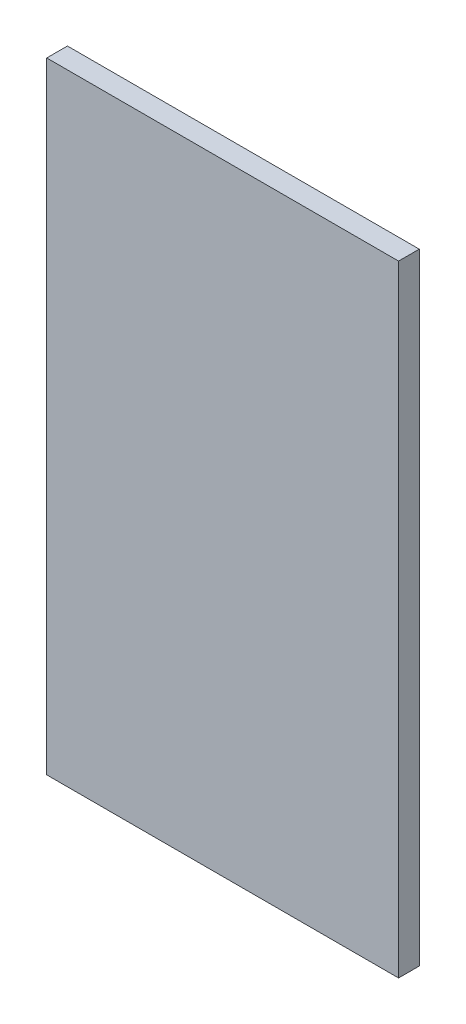
from build123d import *

# Parameters (mm, degrees)
SKETCH_1_W      = 170
SKETCH_1_H      = 300
EXTRUDE_1_DEPTH = 10


with BuildPart() as part:
    # 草图1 → 凸台-拉伸1 (new body)
    with BuildSketch(Plane.XY):
        with Locations((28.417429749, -126.262807225)):
            Rectangle(SKETCH_1_W, SKETCH_1_H)
    extrude(amount=EXTRUDE_1_DEPTH)


solid = part.part
